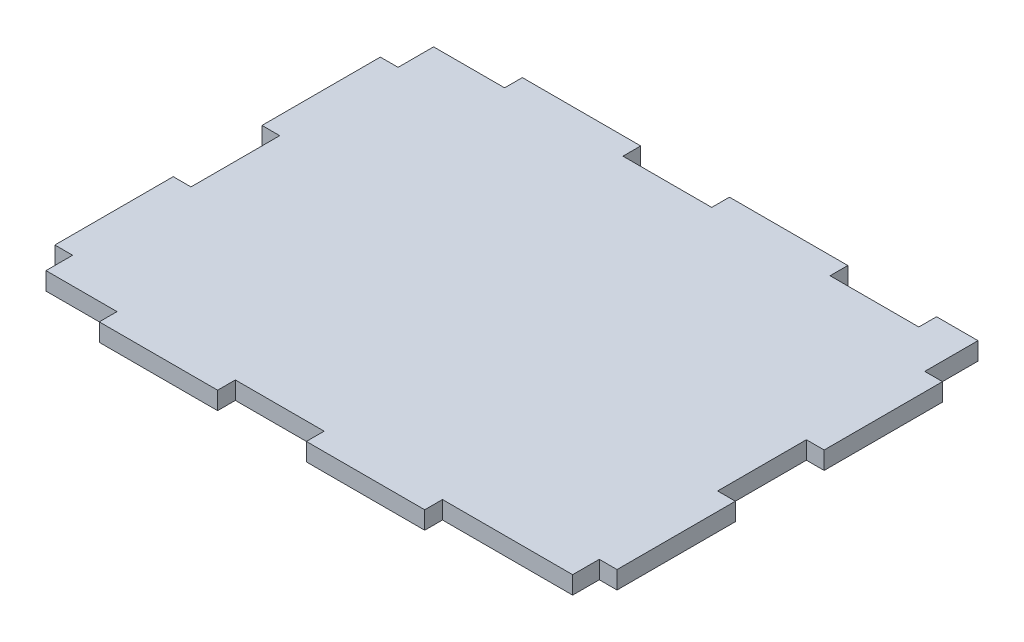
from build123d import *

# Parameters (mm, degrees)
BOSS_EXTRUDE1_DEPTH = 3


with BuildPart() as part:
    # Sketch1 → Boss-Extrude1 (new body)
    with BuildSketch(Plane(origin=(0, 0, 0), x_dir=(1, 0, 0), z_dir=(0, 1, 0))):
        Polygon((12, 65.5), (0, 65.5), (0, 59.5), (-3, 59.5), (-3, 39.5), (0, 39.5), (0, 24.5), (-3, 24.5), (-3, 4.5), (0, 4.5), (0, 0), (12, 0), (12, -3), (32, -3), (32, 0), (47, 0), (47, -3), (67, -3), (67, 0), (89, 0), (89, 4.5), (92, 4.5), (92, 24.5), (89, 24.5), (89, 39.5), (92, 39.5), (92, 59.5), (89, 59.5), (89, 65.5), (89, 68.5), (82, 68.5), (82, 65.5), (67, 65.5), (67, 68.5), (47, 68.5), (47, 65.5), (32, 65.5), (32, 68.5), (12, 68.5), align=None)
    extrude(amount=BOSS_EXTRUDE1_DEPTH)


solid = part.part
